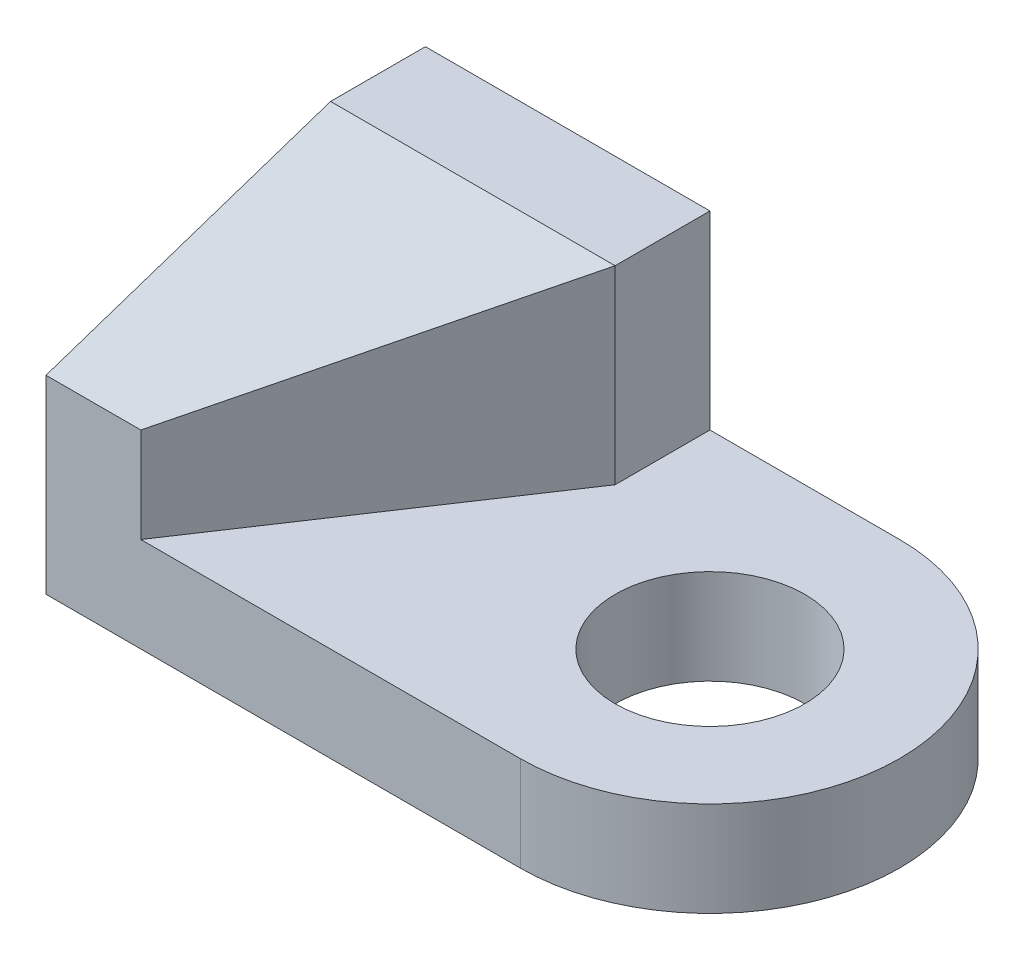
from build123d import *

# Parameters (mm, degrees)
SKETCH_1_R          = 5
EXTRUDE_1_DEPTH     = 5
SKETCH_1_3_W        = 15
SKETCH_1_3_H        = 20
EXTRUDE_2_DEPTH     = 15
CUT_EXTRUDE_1_DEPTH = 15
CUT_EXTRUDE_2_DEPTH = 10


with BuildPart() as part:
    # 草圖1 → 填料-伸長1 (new body)
    with BuildSketch(Plane(origin=(0, 0, 0), x_dir=(1, 0, 0), z_dir=(0, 1, 0))):
        with BuildLine():
            ThreePointArc((0, -10), (10, 0), (0, 10))
            Line((0, 10), (-10, 10))
            Line((-10, 10), (-10, 5))
            Line((-10, 5), (-10, -10))
            Line((-10, -10), (0, -10))
        make_face()
        Circle(SKETCH_1_R, mode=Mode.SUBTRACT)
    extrude(amount=EXTRUDE_1_DEPTH)

    # 草圖1<3> → 填料-伸長2 (add)
    with BuildSketch(Plane(origin=(0, 0, 0), x_dir=(1, 0, 0), z_dir=(0, 1, 0))):
        with Locations((-17.5, 0)):
            Rectangle(SKETCH_1_3_W, SKETCH_1_3_H)
    extrude(amount=EXTRUDE_2_DEPTH)

    # 草圖3 → 除料-伸長1 (cut)
    with BuildSketch(Plane(origin=(-10, 0, 0), x_dir=(0, 0, -1), z_dir=(1, 0, 0))):
        Polygon((5, 15), (-10, 10), (-10, 15), align=None)
    extrude(amount=-CUT_EXTRUDE_1_DEPTH, mode=Mode.SUBTRACT)

    # 草圖2 → 除料-伸長2 (cut)
    with BuildSketch(Plane(origin=(0, 15, 0), x_dir=(1, 0, 0), z_dir=(0, 1, 0))):
        Polygon((-10, 5), (-20, -10), (-10, -10), align=None)
    extrude(amount=-CUT_EXTRUDE_2_DEPTH, mode=Mode.SUBTRACT)


solid = part.part
